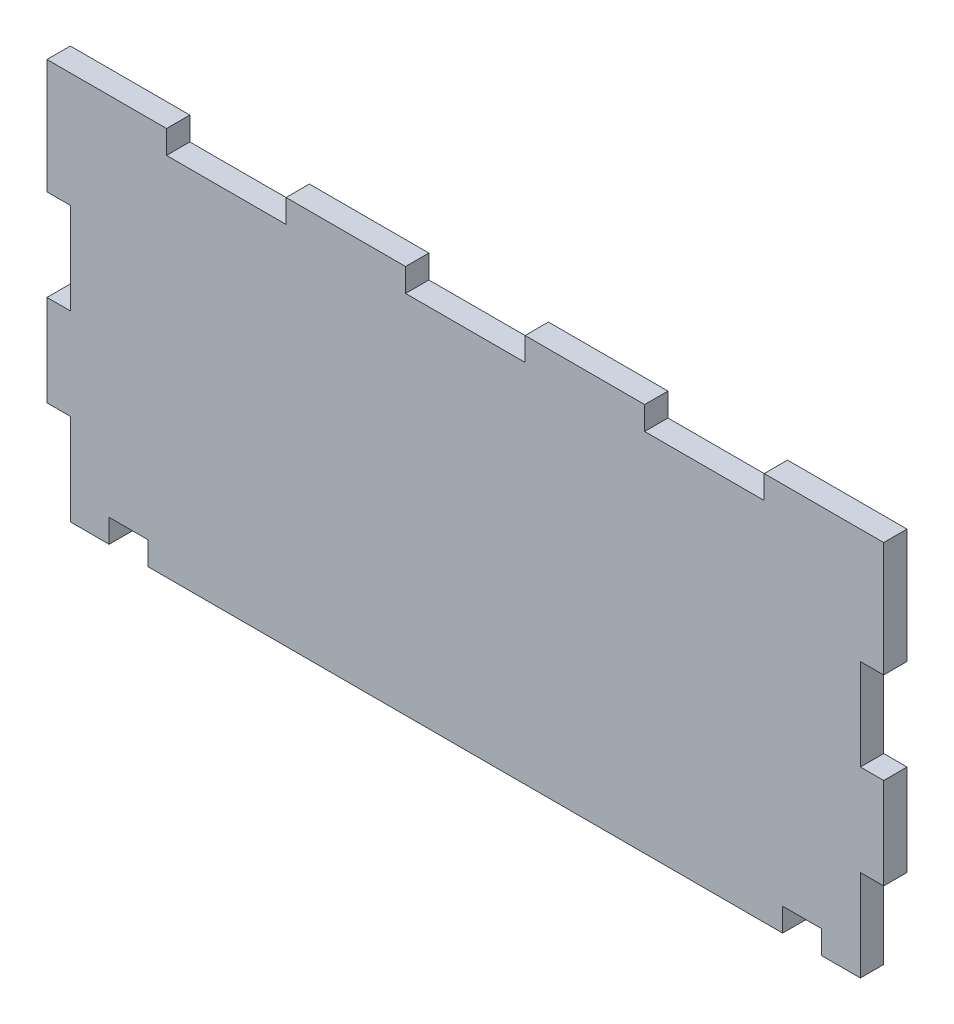
from build123d import *

# Parameters (mm, degrees)
SALIENTE_EXTRUIR1_DEPTH = 3


with BuildPart() as part:
    # Croquis1 → Saliente-Extruir1 (new body)
    with BuildSketch(Plane.XY):
        Polygon((141.617906202, -31.363864653), (146.617906202, -31.363864653), (146.617906202, -28.363864653), (151.617906202, -28.363864653), (151.617906202, -31.363864653), (233.227906202, -31.363864653), (233.227906202, -28.363864653), (238.227906202, -28.363864653), (238.227906202, -31.363864653), (243.227906202, -31.363864653), (243.227906202, -19.613864653), (246.227906202, -19.613864653), (246.227906202, -7.863864653), (243.227906202, -7.863864653), (243.227906202, 3.886135347), (246.227906202, 3.886135347), (246.227906202, 18.636135347), (230.85504906, 18.636135347), (230.85504906, 15.636135347), (215.482191917, 15.636135347), (215.482191917, 18.636135347), (200.109334774, 18.636135347), (200.109334774, 15.636135347), (184.736477631, 15.636135347), (184.736477631, 18.636135347), (169.363620488, 18.636135347), (169.363620488, 15.636135347), (153.990763345, 15.636135347), (153.990763345, 18.636135347), (138.617906202, 18.636135347), (138.617906202, 3.886135347), (141.617906202, 3.886135347), (141.617906202, -7.863864653), (138.617906202, -7.863864653), (138.617906202, -19.613864653), (141.617906202, -19.613864653), align=None)
    extrude(amount=SALIENTE_EXTRUIR1_DEPTH)


solid = part.part
